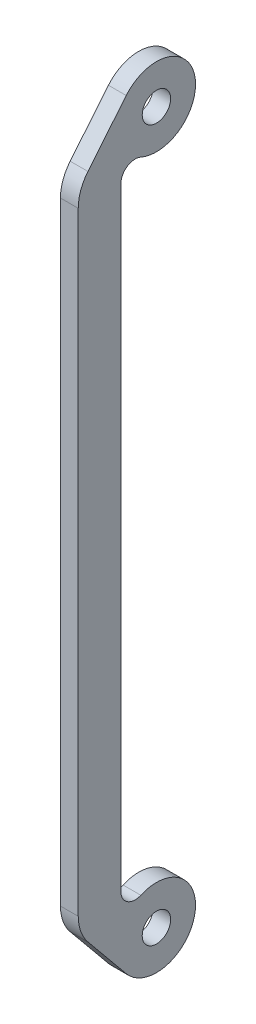
from build123d import *

# Parameters (mm, degrees)
SKETCH1_R             = 4
BOSS_EXTRUDE1_DEPTH   = 5
BODY_MOVE_COPY1_ANGLE = 90


with BuildPart() as part:
    # Sketch1 → Boss-Extrude1 (new body)
    with BuildSketch(Plane(origin=(0, 0, 0), x_dir=(1, 0, 0), z_dir=(0, 1, 0))):
        with BuildLine():
            Line((13.747727104, -9.999999956), (186.252272934, -9.999999956))
            ThreePointArc((186.252272934, -9.999999956), (189.598913044, -8.190890181), (189.918333485, -4.399999944))
            ThreePointArc((189.918333485, -4.399999944), (202.569546944, 10.695673442), (206.982653657, -8.499561542))
            Line((206.982653657, -8.499561542), (193.869713288, -19.272249007))
            ThreePointArc((193.869713288, -19.272249007), (190.297826985, -21.297499344), (186.252273428, -21.999999956))
            Line((186.252273428, -21.999999956), (13.747727597, -21.999999956))
            ThreePointArc((13.747727597, -21.999999956), (9.702173549, -21.297499522), (6.130286801, -19.272249048))
            Line((6.130286801, -19.272249048), (-6.982653611, -8.499561668))
            ThreePointArc((-6.982653611, -8.499561668), (-2.569547007, 10.695673339), (10.081666543, -4.399999968))
            ThreePointArc((10.081666543, -4.399999968), (10.401087001, -8.190890191), (13.747727104, -9.999999956))
        make_face()
        Circle(SKETCH1_R, mode=Mode.SUBTRACT)
        with Locations((200, 8.8e-08)):
            Circle(SKETCH1_R, mode=Mode.SUBTRACT)
    extrude(amount=BOSS_EXTRUDE1_DEPTH)


with BuildPart() as part_1:
    # Body-Move/Copy1: moved
    add(part.part.moved(Location((0, 0, 0))).rotate(Axis((100, 2.5, 0), (0, 0, 1)), BODY_MOVE_COPY1_ANGLE))


solid = part_1.part
